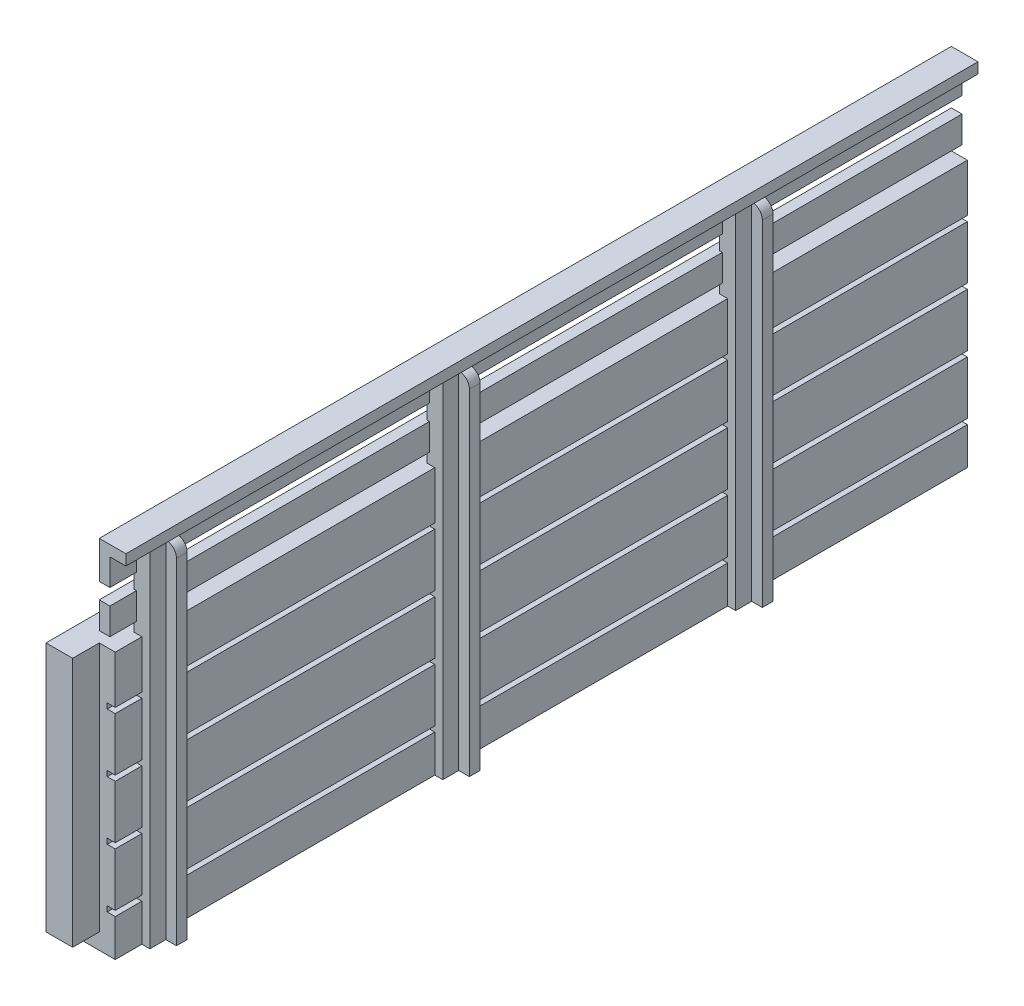
from build123d import *

# Parameters (mm, degrees)
SKETCH1_W             = 160
SKETCH1_H             = 50
BOSS_EXTRUDE1_DEPTH   = 3
SKETCH2_W             = 160
SKETCH2_H             = 1
CUT_EXTRUDE1_DEPTH    = 1.5
SKETCH3_W             = 5
SKETCH3_H             = 65
BOSS_EXTRUDE2_DEPTH   = 1.5
SKETCH4_W             = 2
SKETCH4_H             = 65
BOSS_EXTRUDE3_DEPTH   = 2
FILLET1_R             = 2
SKETCH5_W             = 160
SKETCH5_H             = 5
BOSS_EXTRUDE4_DEPTH   = 2
BOSS_EXTRUDE4_2_DEPTH = 2
SKETCH7_W             = 160
SKETCH7_H             = 3
BOSS_EXTRUDE5_DEPTH   = 5
SKETCH8_W             = 5
SKETCH8_H             = 160
BOSS_EXTRUDE6_DEPTH   = 2
SKETCH11_W            = 10
SKETCH11_H            = 47
BOSS_EXTRUDE7_DEPTH   = 5


with BuildPart() as part:
    # Sketch1 → Boss-Extrude1 (new body)
    with BuildSketch(Plane(origin=(0, 0, 0), x_dir=(0, 0, -1), z_dir=(1, 0, 0))):
        Rectangle(SKETCH1_W, SKETCH1_H)
    extrude(amount=BOSS_EXTRUDE1_DEPTH)

    # Sketch2 → Cut-Extrude1 (cut)
    with BuildSketch(Plane(origin=(3, 0, 0), x_dir=(0, 0, -1), z_dir=(1, 0, 0))):
        with Locations((0, -17.5)):
            Rectangle(SKETCH2_W, SKETCH2_H)
        with Locations((0, -6.5)):
            Rectangle(SKETCH2_W, SKETCH2_H)
        with Locations((0, 4.5)):
            Rectangle(SKETCH2_W, SKETCH2_H)
        with Locations((0, 15.5)):
            Rectangle(SKETCH2_W, SKETCH2_H)
    extrude(amount=-CUT_EXTRUDE1_DEPTH, mode=Mode.SUBTRACT)

    # Sketch3 → Boss-Extrude2 (add, symmetric)
    with BuildSketch(Plane(origin=(3, 0, 0), x_dir=(0, 0, -1), z_dir=(1, 0, 0))):
        with Locations((-72.5, 7.5)):
            Rectangle(SKETCH3_W, SKETCH3_H)
        with Locations((37.5, 7.5)):
            Rectangle(SKETCH3_W, SKETCH3_H)
        with Locations((-17.5, 7.5)):
            Rectangle(SKETCH3_W, SKETCH3_H)
    extrude(amount=BOSS_EXTRUDE2_DEPTH, both=True)

    # Sketch4 → Boss-Extrude3 (add)
    with BuildSketch(Plane(origin=(4.5, 0, 0), x_dir=(0, 0, -1), z_dir=(1, 0, 0))):
        with Locations((39, 7.5)):
            Rectangle(SKETCH4_W, SKETCH4_H)
        with Locations((-16, 7.5)):
            Rectangle(SKETCH4_W, SKETCH4_H)
        with Locations((-71, 7.5)):
            Rectangle(SKETCH4_W, SKETCH4_H)
    extrude(amount=BOSS_EXTRUDE3_DEPTH)

    # Fillet1
    fillet1_edges = [part.edges().sort_by_distance(p)[0] for p in [
        (6.5, 40, 71),
        (6.5, 40, 16),
        (6.5, 40, -39),
    ]]
    fillet(fillet1_edges, radius=FILLET1_R)

    # Sketch7 → Boss-Extrude5 (add)
    with BuildSketch(Plane.ZY):
        with Locations((0, -23.5)):
            Rectangle(SKETCH7_W, SKETCH7_H)
    extrude(amount=BOSS_EXTRUDE5_DEPTH)



with BuildPart() as body_2:
    # Sketch5 → Boss-Extrude4 (new body)
    with BuildSketch(Plane.ZY):
        with Locations((0, 29.5)):
            Rectangle(SKETCH5_W, SKETCH5_H)
    extrude(amount=-BOSS_EXTRUDE4_DEPTH)


with BuildPart() as body_3:
    # Sketch5 → Boss-Extrude4 2 (new body)
    with BuildSketch(Plane.ZY):
        with Locations((0, 37.5)):
            Rectangle(SKETCH5_W, SKETCH5_H)
    extrude(amount=-BOSS_EXTRUDE4_2_DEPTH)


with BuildPart() as part_1:
    add(part.part)

    add(body_3.part)  # Boss-Extrude6 merges body 3
    # Sketch8 → Boss-Extrude6 (add)
    with BuildSketch(Plane(origin=(0, 40, 0), x_dir=(1, 0, 0), z_dir=(0, 1, 0))):
        with Locations((2.5, 0)):
            Rectangle(SKETCH8_W, SKETCH8_H)
    extrude(amount=BOSS_EXTRUDE6_DEPTH)

    # Sketch11 → Boss-Extrude7 (add)
    with BuildSketch(Plane.ZY):
        with Locations((80, 1.5)):
            Rectangle(SKETCH11_W, SKETCH11_H)
    extrude(amount=BOSS_EXTRUDE7_DEPTH)


solid = Compound([body_2.part, part_1.part])
